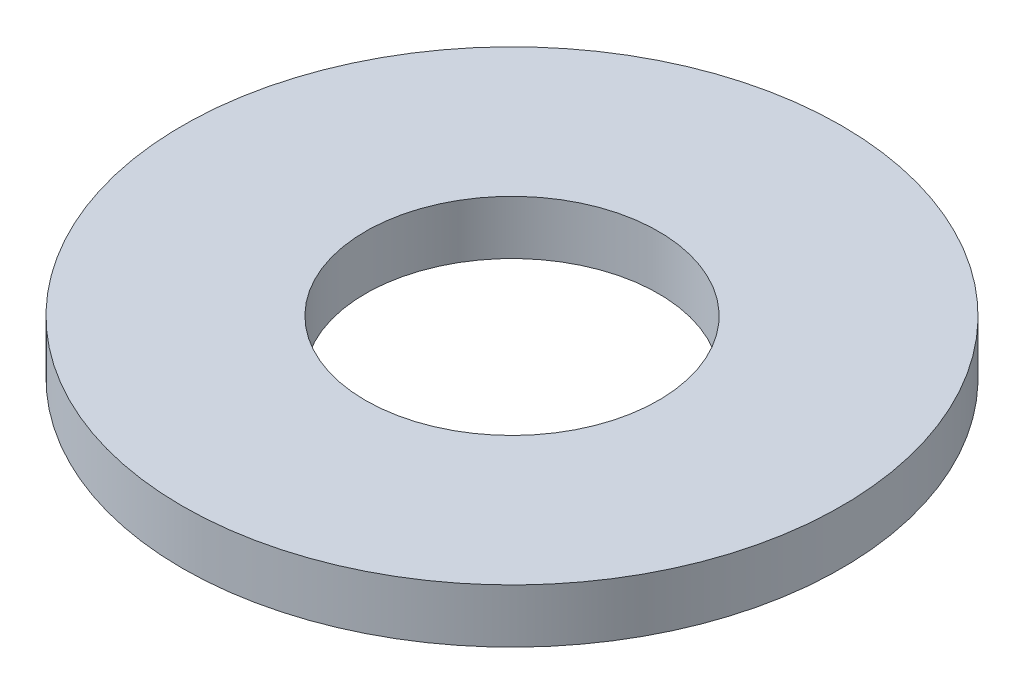
from build123d import *

# Parameters (mm, degrees)
SKETCH1_R           = 14.2875
SKETCH1_R_2         = 6.35
BOSS_EXTRUDE1_DEPTH = 2.3368


with BuildPart() as part:
    # Sketch1 → Boss-Extrude1 (new body)
    with BuildSketch(Plane(origin=(0, 0, 0), x_dir=(1, 0, 0), z_dir=(0, 1, 0))):
        Circle(SKETCH1_R)
        Circle(SKETCH1_R_2, mode=Mode.SUBTRACT)
    extrude(amount=BOSS_EXTRUDE1_DEPTH)


solid = part.part
